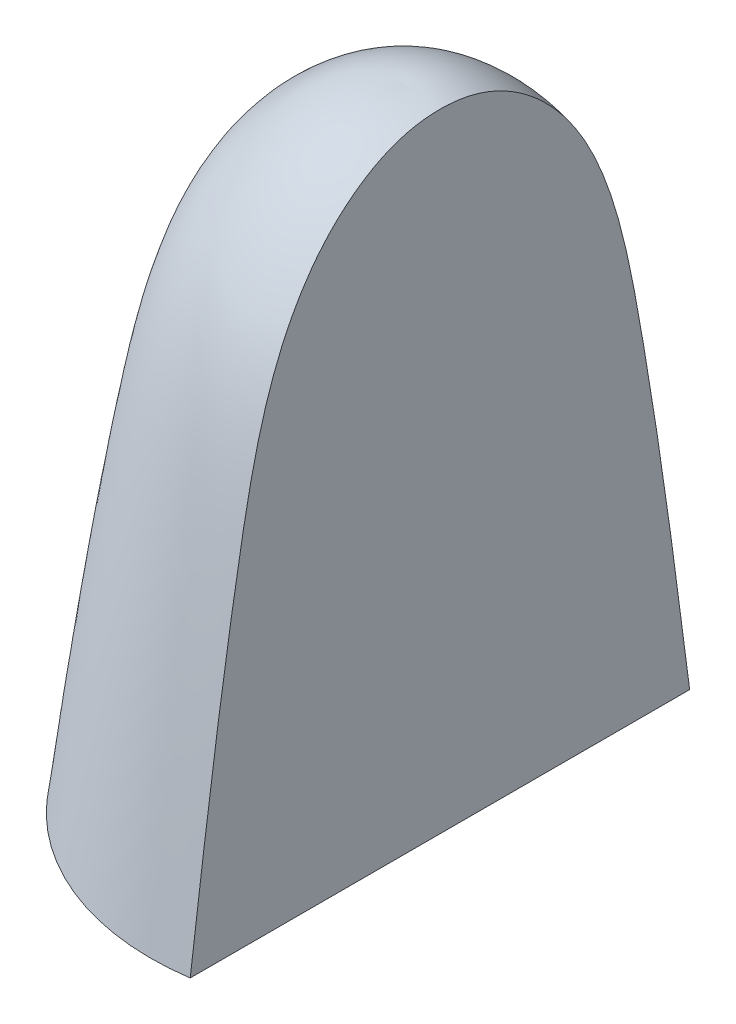
from build123d import *

# Parameters (mm, degrees)
SKETCH5_W                = 5
SKETCH5_H                = 18
CUT_EXTRUDE4_DEPTH       = 20
REVOLVE3_ANGLE           = 90
REVOLVE3_OTHER_WAY_ANGLE = 90
SKETCH12_W               = 15.157920946
SKETCH12_H               = 18.962900337
CUT_EXTRUDE5_DEPTH       = 9


with BuildPart() as part:
    # Sketch1 → Revolve1 (revolve)
    with BuildSketch(Plane.XY):
        with BuildLine():
            Line((4.88, 0), (6.88, 0))
            add(Edge.make_bspline(
                [(6.88, 0), (6.476901655, 3.177692832), (5.808868292, 8.357754247), (4.378289276, 15.464596201), (1.111060579, 17.280233516), (0, 17.2)],
                knots=[0, 0, 0, 0, 0.473754928, 0.838492431, 1, 1, 1, 1], degree=3))
            Line((0, 17.2), (0, 15.4))
            add(Edge.make_bspline(
                [(0, 15.4), (1.563029619, 15.297760208), (2.284243197, 13.63319745)],
                knots=[0, 0, 0, 1, 1, 1], degree=2))
            add(Edge.make_bspline(
                [(2.284243197, 13.63319745), (4.266259497, 7.778351244), (4.88, 1.606249126)],
                knots=[0, 0, 0, 1, 1, 1], degree=2))
            ThreePointArc((4.88, 1.606249126), (4.905839008, 0.803124563), (4.88, 0))
        make_face()
    revolve(axis=Axis((0, 18.057905706, 0), (0, -1, 0)))

    # Sketch5 → Cut-Extrude4 (cut)
    with BuildSketch(Plane.XZ):
        with Locations((4.5, 0.912005105)):
            Rectangle(SKETCH5_W, SKETCH5_H)
    extrude(amount=-CUT_EXTRUDE4_DEPTH, mode=Mode.SUBTRACT)

    # Sketch9 → Revolve3 (revolve)
    with BuildSketch(Plane.XY):
        with BuildLine():
            Line((0, 17.2), (0, 0))
            Line((0, 0), (4.88, 0))
            Line((4.88, 0), (6.88, 0))
            add(Edge.make_bspline(
                [(6.88, 0), (6.476901655, 3.177692832), (5.808868292, 8.357754247), (4.378289276, 15.464596201), (1.111060579, 17.280233516), (0, 17.2)],
                knots=[0, 0, 0, 0, 0.473754928, 0.838492431, 1, 1, 1, 1], degree=3))
        make_face()
    revolve(axis=Axis((0, 17.2, 0), (0, -1, 0)), revolution_arc=REVOLVE3_ANGLE)

    # Sketch9 → Revolve3 other way (revolve)
    with BuildSketch(Plane.XY):
        with BuildLine():
            Line((0, 17.2), (0, 0))
            Line((0, 0), (4.88, 0))
            Line((4.88, 0), (6.88, 0))
            add(Edge.make_bspline(
                [(6.88, 0), (6.476901655, 3.177692832), (5.808868292, 8.357754247), (4.378289276, 15.464596201), (1.111060579, 17.280233516), (0, 17.2)],
                knots=[0, 0, 0, 0, 0.473754928, 0.838492431, 1, 1, 1, 1], degree=3))
        make_face()
    revolve(axis=Axis((0, 17.2, 0), (0, 1, 0)), revolution_arc=REVOLVE3_OTHER_WAY_ANGLE)

    # Sketch12 → Cut-Extrude5 (cut)
    with BuildSketch(Plane(origin=(10, 0, 0), x_dir=(0, 0, -1), z_dir=(1, 0, 0))):
        with Locations((0, 8.631516603)):
            Rectangle(SKETCH12_W, SKETCH12_H)
    extrude(amount=-CUT_EXTRUDE5_DEPTH, mode=Mode.SUBTRACT)


solid = part.part
